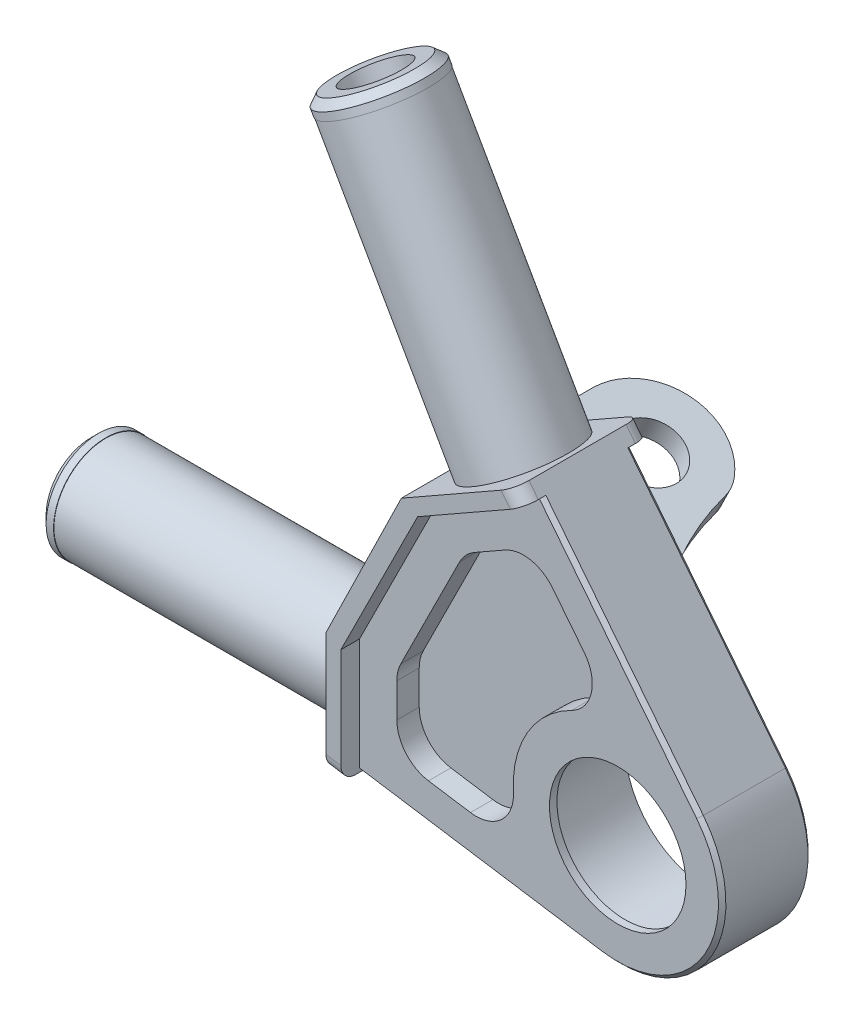
from build123d import *

# Parameters (mm, degrees)
SZKIC1_R                         = 11
DODANIE_WYCI_GNI_CIE1_DEPTH      = 12
SZKIC4_R                         = 11.147474951019817
SZKIC4_R_2                       = 9.147474951019817
DODANIE_WYCI_GNI_CIE2_DEPTH      = 1
SZKIC13_R                        = 4.000000000000003
DODANIE_WYCI_GNI_CIE3_DEPTH      = 11.5
WYTNIJ_WYCI_GNI_CIE1_DEPTH       = 60.02626138756585
WYTNIJ_WYCI_GNI_CIE2_DEPTH       = 58.227067591020045
WYTNIJ_WYCI_GNI_CIE3_DEPTH       = 23
DODANIE_WYCI_GNI_CIE4_DEPTH      = 2.5
DODANIE_WYCI_GNI_CIE4_DEPTH_BACK = 14.5
DODANIE_WYCI_GNI_CIE5_DEPTH      = 2.5
OTWORY_USTALAJ_CE_8_0MM1_D       = 8
OTWORY_USTALAJ_CE_8_0MM1_DEPTH   = 40
OTWORY_USTALAJ_CE_8_0MM1_TIP     = 2.403442476110241
OTWORY_USTALAJ_CE_8_0MM2_D       = 8
OTWORY_USTALAJ_CE_8_0MM2_DEPTH   = 40
OTWORY_USTALAJ_CE_8_0MM2_TIP     = 2.403442476110241
SFAZOWANIE1_SIZE                 = 1
ZAOKR_GLENIE2_R                  = 2
ZAOKR_GLENIE3_R                  = 5
SFAZOWANIE2_SIZE                 = 0.5
ZAOKR_GLENIE4_R                  = 0.3
ZAOKR_GLENIE5_R                  = 5
WYTNIJ_WYCI_GNI_CIE4_START       = -3
WYTNIJ_WYCI_GNI_CIE4_DEPTH       = 3
ZAOKR_GLENIE11_R                 = 5


with BuildPart() as part:
    # Szkic1 → Dodanie-wyciągnięcie1 (new body)
    with BuildSketch(Plane.XY):
        with BuildLine():
            Line((-40, -8.000000000000005), (-2.1326786841408407, -13.836606579295779))
            ThreePointArc((-2.1326786841408407, -13.836606579295779), (12.103611293588447, -7.035807960264275), (10.968141143659846, 8.700567789101818))
            Line((10.968141143659846, 8.700567789101818), (-12.843130370941623, 38.71761875780841))
            Line((-12.843130370941623, 38.71761875780841), (-26.746589095410883, 30.799674864537906))
            Line((-26.746589095410883, 30.799674864537906), (-40, 7.999999999999995))
            Line((-40, 7.999999999999995), (-40, -8.000000000000005))
        make_face()
        Circle(SZKIC1_R, mode=Mode.SUBTRACT)
    extrude(amount=DODANIE_WYCI_GNI_CIE1_DEPTH)

    # Szkic4 → Dodanie-wyciągnięcie2 (add)
    with BuildSketch(Plane.XY.offset(12)):
        Circle(SZKIC4_R)
        Circle(SZKIC4_R_2, mode=Mode.SUBTRACT)
    extrude(amount=-DODANIE_WYCI_GNI_CIE2_DEPTH)

    # Szkic13 → Dodanie-wyciągnięcie3 (add, symmetric)
    with BuildSketch(Plane(origin=(0.996619630552348, 2.0368751739166404, 3.1e-16), x_dir=(0.8982426752029381, -0.43949982530630105, 0), z_dir=(0.4394998253063011, 0.8982426752029382, 0))):
        with BuildLine():
            Line((-36.22413445269548, 11.122577076374291), (-36.22413445269548, 8.67e-15))
            Line((-36.22413445269548, 8.67e-15), (-33.72413445269548, 7.61e-15))
            Line((-33.72413445269548, 7.61e-15), (-13.224134452695484, 6.94e-15))
            ThreePointArc((-13.224134452695484, 6.94e-15), (-17.80107386619313, 7.230855656561982), (-20.374424199879662, 15.392443491106029))
            ThreePointArc((-20.374424199879662, 15.392443491106029), (-29.935182038237862, 19.329968170654332), (-36.22413445269548, 11.122577076374291))
        make_face()
        with Locations(Location((-27.724134452695484, 11.122577076374293, 0), (0, 0, 180))):
            Circle(SZKIC13_R, mode=Mode.SUBTRACT)
    extrude(amount=DODANIE_WYCI_GNI_CIE3_DEPTH, both=True)

    # Szkic15 → Wytnij-wyciągnięcie1 (cut, through all)
    with BuildSketch(Plane(origin=(0, 0, 0), x_dir=(-1, 0, 0), z_dir=(0, 0, -1))):
        Polygon((12.843130370941623, 38.71761875780841), (26.746589095410883, 30.799674864537906), (40, 7.999999999999995), (40, -8.000000000000005), (38.494484112785884, -8.232049789295985), (38.494484112785884, 7.999999999999995), (26.00155220007409, 29.491432489730776), (12.09809347560483, 37.40937638300129), (11.896450058886177, 37.52421120875695), align=None)
    extrude(amount=-WYTNIJ_WYCI_GNI_CIE1_DEPTH, mode=Mode.SUBTRACT)

    # Szkic16 → Wytnij-wyciągnięcie2 (cut, through all)
    with BuildSketch(Plane(origin=(0, 0, 0), x_dir=(-1, 0, 0), z_dir=(0, 0, -1))):
        Polygon((26.48719581612529, 28.287166702582056), (36.59569179817021, 7.627585172914479), (36.59569179817021, -8.524716482663612), (38.494484112785884, -8.232049789295985), (38.494484112785884, 7.999999999999995), (26.00155220007409, 29.491432489730776), (11.896450058886177, 37.52421120875695), (11.389545957202317, 36.88519593201458), align=None)
    extrude(amount=-WYTNIJ_WYCI_GNI_CIE2_DEPTH, mode=Mode.SUBTRACT)

    # Szkic17 → Wytnij-wyciągnięcie3 (cut)
    with BuildSketch(Plane(origin=(-32.53806343770011, 15.920500763831628, 0), x_dir=(0, 0, 1), z_dir=(-0.898242675202938, 0.4394998253063012, 0))):
        Polygon((-27.81416800588854, 10.767622358797922), (-27.814168005888536, -7.232377641202076), (1.18e-15, -7.232377641202076), (2.5, -7.232377641202076), (2.5000000000000004, 10.767622358797922), (4.3e-16, 10.767622358797922), align=None)
    extrude(amount=-WYTNIJ_WYCI_GNI_CIE3_DEPTH, mode=Mode.SUBTRACT)

    # Szkic18 → Obrót1 (revolve)
    with BuildSketch(Plane(origin=(0, 0, 6), x_dir=(-1, 0, 0), z_dir=(0, 0, -1)), mode=Mode.PRIVATE) as obr_t1_sk:
        Polygon((76.59569179817022, 0), (76.59569179817021, -7), (74.59569179817021, -7), (74.59569179817021, -6.95), (36.59569179817021, -6.949999999999999), (36.59569179817021, 0), align=None)
    revolve(obr_t1_sk.sketch.rotate(Axis((0, 0, 6), (-1, 0, 0)), 270), axis=Axis((0, 0, 6), (-1, 0, 0)))

    # Szkic19 → Obrót2 (revolve)
    with BuildSketch(Plane(origin=(0, 0, 6), x_dir=(-1, 0, 0), z_dir=(0, 0, -1))):
        Polygon((38.44574931620652, 67.5085471625366), (32.36298612425123, 70.97264761584243), (31.373243137592404, 69.23471527528378), (31.416691446106377, 69.20997170061732), (12.611574699588953, 36.18925723000281), (18.65088517799791, 32.74989261638888), align=None)
    revolve(axis=Axis((0, 0, 6), (-0.4948714933294059, 0.868966170279329, 0)))

    # Szkic20 → Dodanie-wyciągnięcie4 (add, two sides: drawn at the far end of the back side and taken through both)
    with BuildSketch(Plane(origin=(0, 0, 0), x_dir=(-1, 0, 0), z_dir=(0, 0, -1)).offset(-DODANIE_WYCI_GNI_CIE4_DEPTH_BACK)):
        Polygon((36.59569179817021, -8.524716482663612), (34.59569179817021, -8.832982627533559), (34.59569179817021, 6.649008141474715), (36.59569179817021, 7.627585172914479), align=None)
        Polygon((26.48719581612529, 28.287166702582056), (11.389545957202317, 36.88519593201458), (10.13193011920909, 35.29981571891061), (24.31339302460761, 27.223549961252633), align=None)
    extrude(amount=DODANIE_WYCI_GNI_CIE4_DEPTH + DODANIE_WYCI_GNI_CIE4_DEPTH_BACK)

    # Szkic21 → Dodanie-wyciągnięcie5 (add)
    with BuildSketch(Plane.XY.offset(12)):
        Polygon((-24.313393024607603, 27.22354996125263), (-26.48719581612529, 28.287166702582056), (-36.59569179817021, 7.627585172914479), (-34.59569179817021, 6.649008141474715), align=None)
    extrude(amount=DODANIE_WYCI_GNI_CIE5_DEPTH)

    # Otwory ustalające Ø8.0mm1
    with Locations(Plane(origin=(-76.595691798, 0, 6), x_dir=(0, 0, -1), z_dir=(-1, 0, 0))):
        with Locations((0, 0)):
            Hole(OTWORY_USTALAJ_CE_8_0MM1_D / 2, depth=OTWORY_USTALAJ_CE_8_0MM1_DEPTH)
            with Locations((0, 0, -(OTWORY_USTALAJ_CE_8_0MM1_DEPTH + OTWORY_USTALAJ_CE_8_0MM1_TIP / 2))):  # 118° drill point
                Cone(0, OTWORY_USTALAJ_CE_8_0MM1_D / 2, OTWORY_USTALAJ_CE_8_0MM1_TIP, mode=Mode.SUBTRACT)

    # Otwory ustalające Ø8.0mm2
    with Locations(Plane(origin=(-38.445749316, 67.508547163, 6), x_dir=(0.868966170279, 0.494871493329, 0), z_dir=(-0.494871493329, 0.868966170279, 0))):
        with Locations((0, 0)):
            Hole(OTWORY_USTALAJ_CE_8_0MM2_D / 2, depth=OTWORY_USTALAJ_CE_8_0MM2_DEPTH)
            with Locations((0, 0, -(OTWORY_USTALAJ_CE_8_0MM2_DEPTH + OTWORY_USTALAJ_CE_8_0MM2_TIP / 2))):  # 118° drill point
                Cone(0, OTWORY_USTALAJ_CE_8_0MM2_D / 2, OTWORY_USTALAJ_CE_8_0MM2_TIP, mode=Mode.SUBTRACT)

    # Sfazowanie1
    sfazowanie1_edges = [part.edges().sort_by_distance(p)[0] for p in [
        (-76.59569179817021, -2.41e-15, 13),
        (-44.52851250816182, 64.04444670923077, 5.999999999999999),
    ]]
    chamfer(sfazowanie1_edges, length=SFAZOWANIE1_SIZE)

    # Zaokrąglenie2
    zaokr_glenie2_edges = [part.edges().sort_by_distance(p)[0] for p in [
        (-35.59569179817021, -8.678849555098585, 14.5),
        (-35.59569179817021, -8.678849555098585, -2.5),
        (-10.760738038205703, 36.092505825462595, 14.5),
        (-10.760738038205703, 36.092505825462595, -2.5),
    ]]
    fillet(zaokr_glenie2_edges, radius=ZAOKR_GLENIE2_R)

    # Zaokrąglenie3
    zaokr_glenie3_edges = [part.edges().sort_by_distance(p)[0] for p in [
        (-7.146113762376627, 15.483942694928315, 1.249999999999997),
        (-15.057110617890048, -0.6844254587245677, 1.2499999999999964),
        (-34.59569179817021, 6.649008141474715, -1.250000000000004),
        (-24.31339302460761, 27.223549961252633, -1.2500000000000024),
    ]]
    fillet(zaokr_glenie3_edges, radius=ZAOKR_GLENIE3_R)

    # Sfazowanie2
    sfazowanie2_edges = [part.edges().sort_by_distance(p)[0] for p in [
        (-18.364185241155525, -11.334794603414672, 12),
        (-18.364185241155525, -11.334794603414672, 0),
        (12.103611293588445, -7.0358079602642745, 12),
        (0.41810551222537384, 22.000191754006217, 0),
        (12.103611293588445, -7.0358079602642745, 0),
        (0.41810551222537384, 22.000191754006217, 12),
    ]]
    chamfer(sfazowanie2_edges, length=SFAZOWANIE2_SIZE)

    # Zaokrąglenie4
    zaokr_glenie4_edges = [part.edges().sort_by_distance(p)[0] for p in [
        (-11, -6.23e-15, 11),
    ]]
    fillet(zaokr_glenie4_edges, radius=ZAOKR_GLENIE4_R)

    # Zaokrąglenie5
    zaokr_glenie5_edges = [part.edges().sort_by_distance(p)[0] for p in [
        (-12.909559415404027, 19.973857802509606, -15.392443491106027),
        (-21.9193058341832, 1.5598829608493752, -15.39244349110603),
    ]]
    fillet(zaokr_glenie5_edges, radius=ZAOKR_GLENIE5_R)

    # Szkic29 → Wytnij-wyciągnięcie4 (cut)
    with BuildSketch(Plane.XY.offset(12).offset(WYTNIJ_WYCI_GNI_CIE4_START)):
        with BuildLine():
            Line((-29.59569179817021, -4.544604097780221), (-29.595691798170208, 5.469178555653164))
            Line((-29.595691798170208, 5.469178555653164), (-20.51960657313938, 23.630126718567237))
            Line((-20.51960657313938, 23.630126718567237), (-11.384028520269917, 28.832788580533173))
            Line((-11.384028520269917, 28.832788580533173), (0.386433954908492, 13.99466572657217))
            ThreePointArc((0.386433954908492, 13.99466572657217), (-12.103611293588447, 7.035807960264281), (-11.969655932420048, -7.261359160617354))
            Line((-11.969655932420048, -7.261359160617354), (-29.59569179817021, -4.544604097780221))
        make_face()
    extrude(amount=WYTNIJ_WYCI_GNI_CIE4_DEPTH, mode=Mode.SUBTRACT)

    # Zaokrąglenie11
    zaokr_glenie11_edges = [part.edges().sort_by_distance(p)[0] for p in [
        (0.386433954908492, 13.99466572657217, 10.5),
        (-11.96965593242005, -7.261359160617353, 10.5),
        (-29.59569179817021, -4.544604097780221, 10.5),
        (-29.595691798170208, 5.469178555653164, 10.5),
        (-20.51960657313938, 23.630126718567237, 10.5),
        (-11.384028520269917, 28.832788580533173, 10.5),
    ]]
    fillet(zaokr_glenie11_edges, radius=ZAOKR_GLENIE11_R)


solid = part.part
